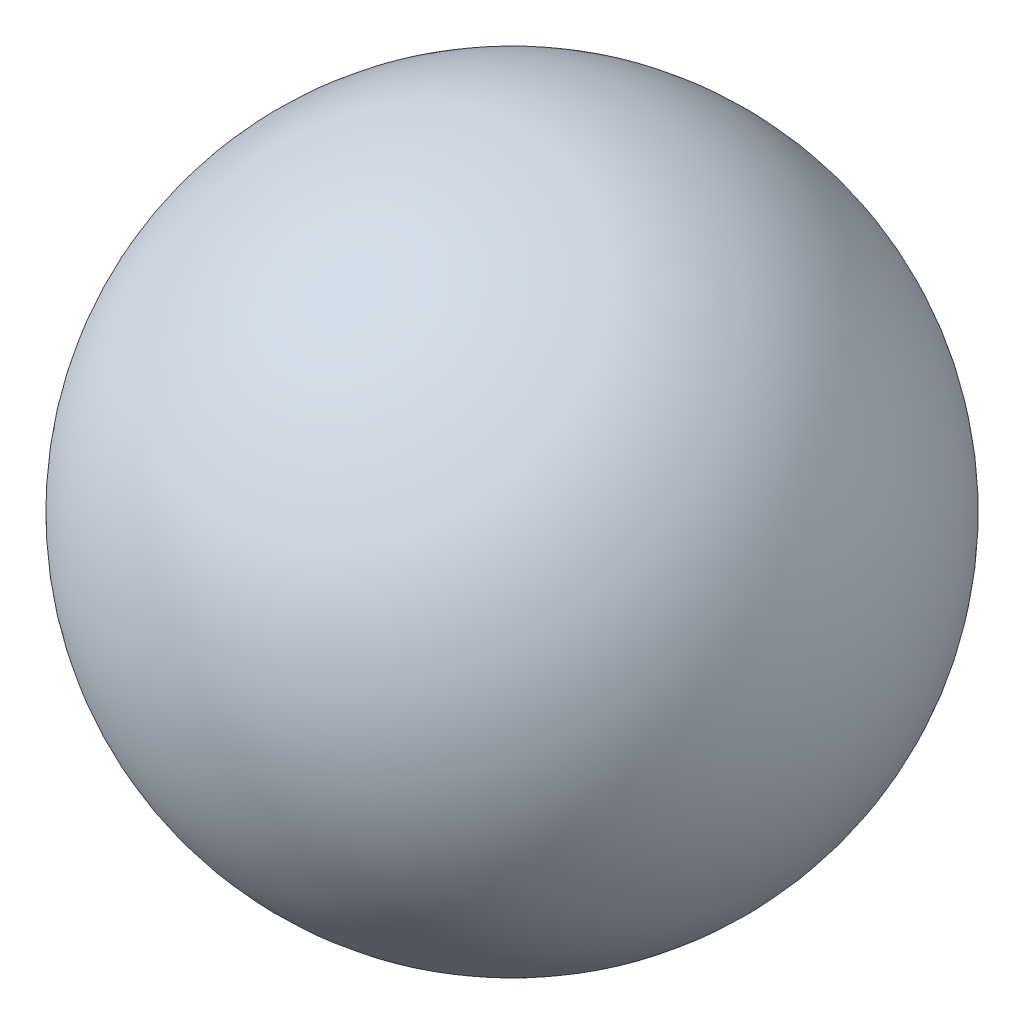
from build123d import *


with BuildPart() as part:
    # Sketch1 → Revolve1 (revolve)
    with BuildSketch(Plane.XY):
        with BuildLine():
            Line((0, 21), (0, -21))
            ThreePointArc((0, -21), (21, 0), (0, 21))
        make_face()
    revolve(axis=Axis((0, 21, 0), (0, -1, 0)))


solid = part.part
